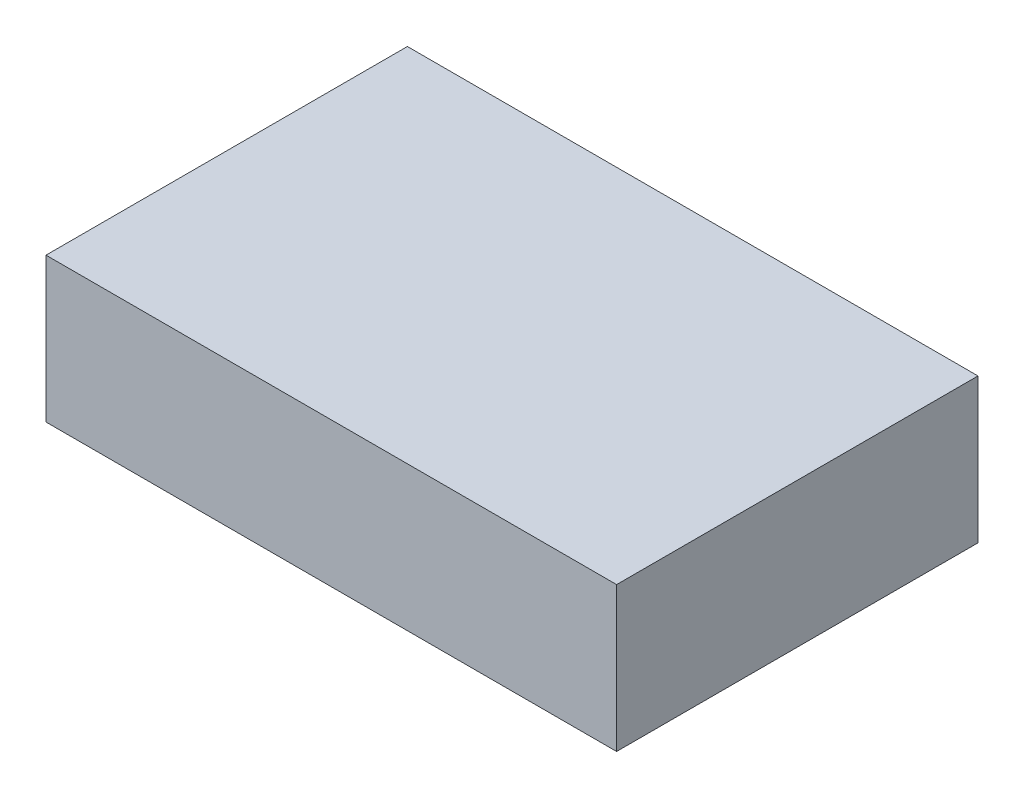
from build123d import *

# Parameters (mm, degrees)
SKETCH1_W           = 38.1
SKETCH1_H           = 24.13
BOSS_EXTRUDE1_DEPTH = 9.652


with BuildPart() as part:
    # Sketch1 → Boss-Extrude1 (new body)
    with BuildSketch(Plane(origin=(0, 0, 0), x_dir=(1, 0, 0), z_dir=(0, 1, 0))):
        Rectangle(SKETCH1_W, SKETCH1_H)
    extrude(amount=BOSS_EXTRUDE1_DEPTH)


solid = part.part
